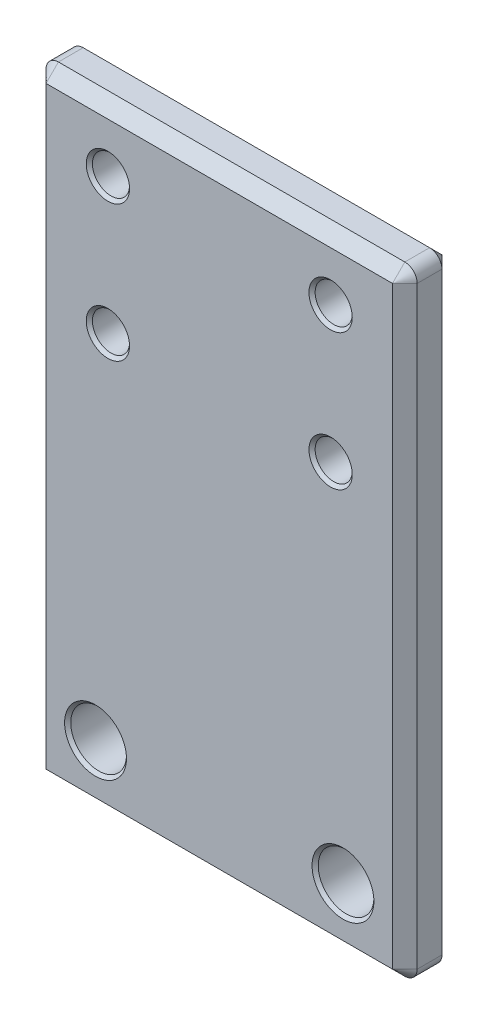
from build123d import *

# Parameters (mm, degrees)
SKETCH1_W                      = 30
SKETCH1_H                      = 50
BOSS_EXTRUDE1_DEPTH            = 4
F_3_0MM_DOWEL_HOLE1_AT_2_COUNT = 2
F_3_0MM_DOWEL_HOLE1_AT_2_PITCH = 11
F_3_0MM_DOWEL_HOLE1_AT_3_COUNT = 2
F_3_0MM_DOWEL_HOLE1_AT_3_PITCH = 21.09502311
F_3_0MM_DOWEL_HOLE1_AT_4_COUNT = 2
F_3_0MM_DOWEL_HOLE1_AT_4_PITCH = 18
M4_CLEARANCE_HOLE1_AT_2_COUNT  = 2
M4_CLEARANCE_HOLE1_AT_2_PITCH  = 20
FILLET1_R                      = 1
CHAMFER1_SIZE                  = 1


with BuildPart() as part:
    # Sketch1 → Boss-Extrude1 (new body)
    with BuildSketch(Plane.XY):
        with Locations((0, -14.5)):
            Rectangle(SKETCH1_W, SKETCH1_H)
    extrude(amount=BOSS_EXTRUDE1_DEPTH)

    # Sketch5 → Ø3.0mm Dowel Hole1 (revolve, cut)
    with BuildSketch(Plane(origin=(-9, 5.5, 4), x_dir=(0, -1, 0), z_dir=(1, 0, 0))):
        Polygon((0, 0), (0, 4), (1.75, 4), (1.5, 3.75), (1.5, 0.25), (1.75, 0), align=None)
    f_3_0mm_dowel_hole1 = revolve(axis=Axis((-9, 5.5, 10.35), (0, 0, -1)), mode=Mode.SUBTRACT)

    # Ø3.0mm Dowel Hole1 at 2: Ø3.0mm Dowel Hole1 ×2
    with Locations(*[(0, -i * F_3_0MM_DOWEL_HOLE1_AT_2_PITCH, 0) for i in range(1, F_3_0MM_DOWEL_HOLE1_AT_2_COUNT)]):
        add(f_3_0mm_dowel_hole1, mode=Mode.SUBTRACT)

    # Ø3.0mm Dowel Hole1 at 3: Ø3.0mm Dowel Hole1 ×2
    with Locations(*[Vector(0.8532818336519591, -0.521450009453975, 0) * (i * F_3_0MM_DOWEL_HOLE1_AT_3_PITCH) for i in range(1, F_3_0MM_DOWEL_HOLE1_AT_3_COUNT)]):
        add(f_3_0mm_dowel_hole1, mode=Mode.SUBTRACT)

    # Ø3.0mm Dowel Hole1 at 4: Ø3.0mm Dowel Hole1 ×2
    with Locations(*[(i * F_3_0MM_DOWEL_HOLE1_AT_4_PITCH, 0, 0) for i in range(1, F_3_0MM_DOWEL_HOLE1_AT_4_COUNT)]):
        add(f_3_0mm_dowel_hole1, mode=Mode.SUBTRACT)

    # Sketch8 → M4 Clearance Hole1 (revolve, cut)
    with BuildSketch(Plane(origin=(-10, -34.5, 4), x_dir=(0, -1, 0), z_dir=(1, 0, 0))):
        Polygon((0, 0), (0, 4), (2.5, 4), (2.25, 3.75), (2.25, 0.25), (2.5, 0), align=None)
    m4_clearance_hole1 = revolve(axis=Axis((-10, -34.5, 10.35), (0, 0, -1)), mode=Mode.SUBTRACT)

    # M4 Clearance Hole1 at 2: M4 Clearance Hole1 ×2
    with Locations(*[(i * M4_CLEARANCE_HOLE1_AT_2_PITCH, 0, 0) for i in range(1, M4_CLEARANCE_HOLE1_AT_2_COUNT)]):
        add(m4_clearance_hole1, mode=Mode.SUBTRACT)

    # Fillet1
    fillet1_edges = [part.edges().sort_by_distance(p)[0] for p in [
        (15, 10.5, 2),
        (15, -39.5, 2),
        (-15, -39.5, 2),
        (-15, 10.5, 2),
    ]]
    fillet(fillet1_edges, radius=FILLET1_R)

    # Chamfer1
    chamfer1_edges = [part.edges().sort_by_distance(p)[0] for p in [
        (0, -39.5, 0),
        (14.707106781, -39.207106781, 0),
        (-14.707106781, -39.207106781, 0),
        (15, -14.5, 0),
        (-15, -14.5, 0),
        (14.707106781, 10.207106781, 0),
        (-14.707106781, 10.207106781, 0),
        (0, 10.5, 0),
        (0, -39.5, 4),
        (14.707106781, -39.207106781, 4),
        (-14.707106781, -39.207106781, 4),
        (15, -14.5, 4),
        (-15, -14.5, 4),
        (14.707106781, 10.207106781, 4),
        (-14.707106781, 10.207106781, 4),
        (0, 10.5, 4),
    ]]
    chamfer(chamfer1_edges, length=CHAMFER1_SIZE)


solid = part.part
